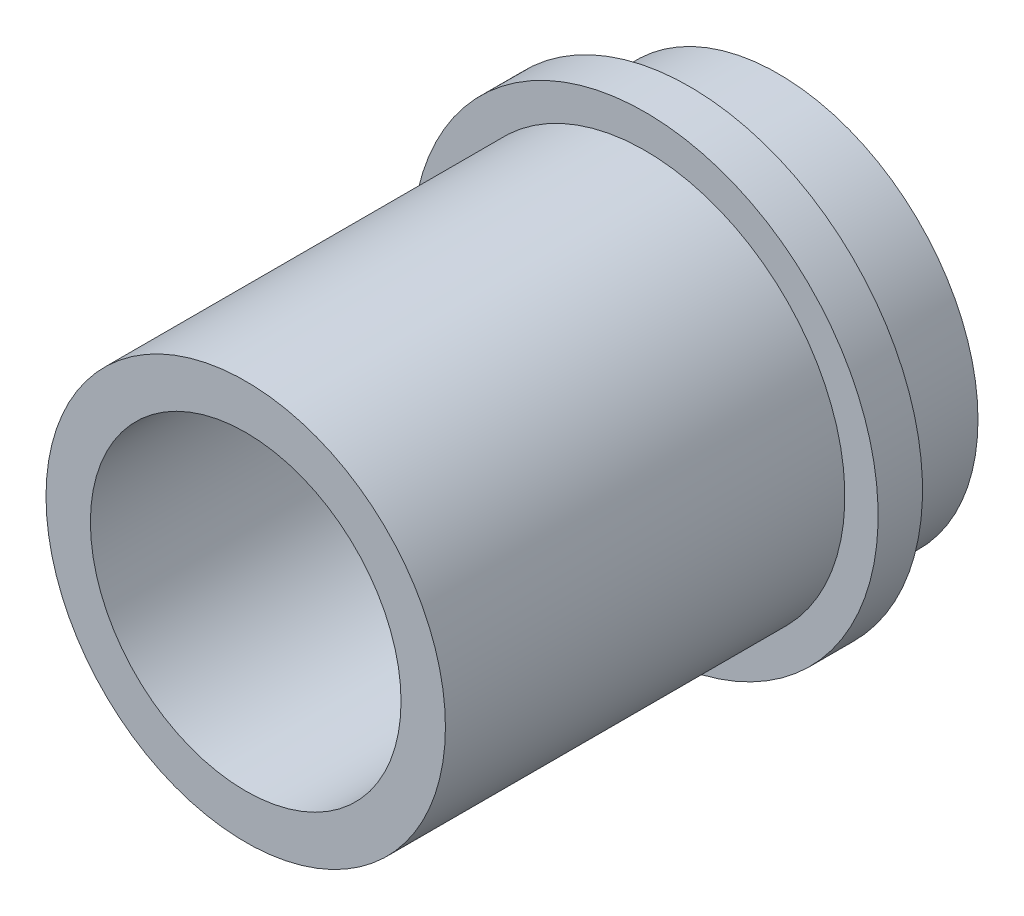
from build123d import *

# Parameters (mm, degrees)
BOSS_EXTRUDE1_START = 8
SKETCH1_R           = 4.5
SKETCH1_R_2         = 3.5
BOSS_EXTRUDE1_DEPTH = 12
BOSS_EXTRUDE2_START = -2
SKETCH2_R           = 5.25
SKETCH2_R_2         = 3.5
BOSS_EXTRUDE2_DEPTH = 1


with BuildPart() as part:
    # Sketch1 → Boss-Extrude1 (new body)
    with BuildSketch(Plane.XY.offset(BOSS_EXTRUDE1_START)):
        Circle(SKETCH1_R)
        Circle(SKETCH1_R_2, mode=Mode.SUBTRACT)
    extrude(amount=BOSS_EXTRUDE1_DEPTH)

    # Sketch2 → Boss-Extrude2 (add)
    with BuildSketch(Plane(origin=(0, 0, 8), x_dir=(-1, 0, 0), z_dir=(0, 0, -1)).offset(BOSS_EXTRUDE2_START)):
        Circle(SKETCH2_R)
        Circle(SKETCH2_R_2, mode=Mode.SUBTRACT)
    extrude(amount=-BOSS_EXTRUDE2_DEPTH)


solid = part.part
